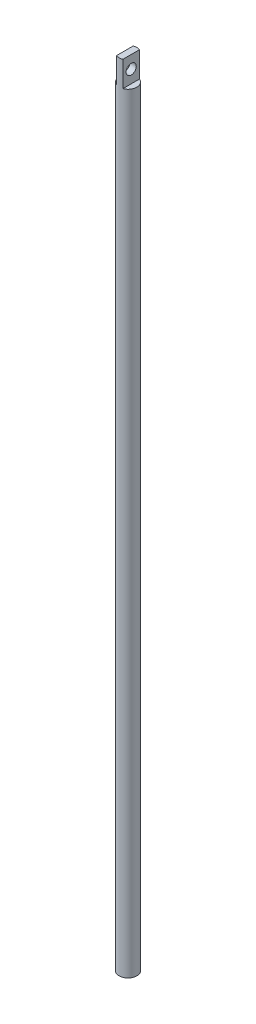
from build123d import *

# Parameters (mm, degrees)
SKETCH_1_R           = 7
EXTRUDE_1_DEPTH      = 15
SKETCH_2_R           = 7
EXTRUDE_2_DEPTH      = 610
SKETCH_3_OUTSIDE_W   = 141.062
SKETCH_3_OUTSIDE_H   = 141.062
SKETCH_3_OUTSIDE_W_2 = 5
SKETCH_3_OUTSIDE_H_2 = 20
CUT_EXTRUDE_1_DEPTH  = 20
SKETCH_4_R           = 4
CUT_EXTRUDE_2_DEPTH  = 20


with BuildPart() as part:
    # 草图1 → 凸台-拉伸1 (new body)
    with BuildSketch(Plane(origin=(0, 0, 0), x_dir=(1, 0, 0), z_dir=(0, 1, 0))):
        Circle(SKETCH_1_R)
    extrude(amount=EXTRUDE_1_DEPTH)

    # 草图2 → 凸台-拉伸2 (add)
    with BuildSketch(Plane(origin=(0, 15, 0), x_dir=(1, 0, 0), z_dir=(0, 1, 0))):
        Circle(SKETCH_2_R)
    extrude(amount=EXTRUDE_2_DEPTH)

    # 草图3 outside → 切除-拉伸1 (cut)
    with BuildSketch(Plane(origin=(0, 625, 0), x_dir=(1, 0, 0), z_dir=(0, 1, 0))):
        Rectangle(SKETCH_3_OUTSIDE_W, SKETCH_3_OUTSIDE_H)
        Rectangle(SKETCH_3_OUTSIDE_W_2, SKETCH_3_OUTSIDE_H_2, mode=Mode.SUBTRACT)
    extrude(amount=-CUT_EXTRUDE_1_DEPTH, mode=Mode.SUBTRACT)

    # 草图4 → 切除-拉伸2 (cut)
    with BuildSketch(Plane.ZY.offset(2.5)):
        with Locations((0, 615)):
            Circle(SKETCH_4_R)
    extrude(amount=-CUT_EXTRUDE_2_DEPTH, mode=Mode.SUBTRACT)


solid = part.part
